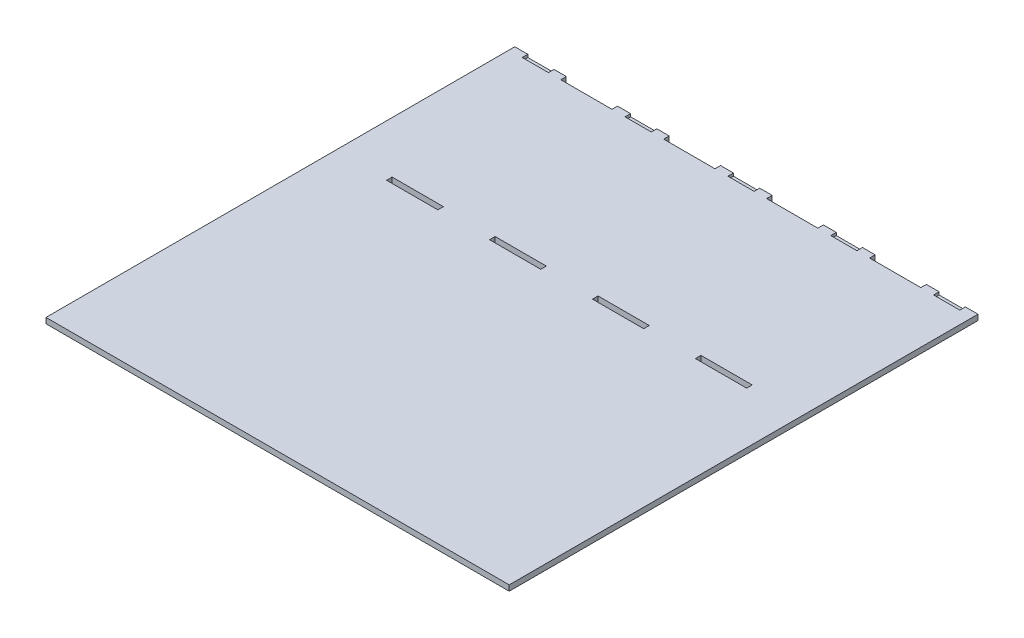
from build123d import *

# Parameters (mm, degrees)
SKETCH2_W              = 500
SKETCH2_H              = 506
BOSS_EXTRUDE1_DEPTH    = 6
CUT_EXTRUDE1_DEPTH     = 6
LPATTERN1_COUNT        = 4
LPATTERN1_PITCH        = 111.1
LPATTERN2_COUNT        = 2
LPATTERN2_PITCH        = 188
LPATTERN3_COPY_1_DEPTH = 6
LPATTERN3_COPY_2_DEPTH = 6
LPATTERN3_COPY_3_DEPTH = 6
SKETCH9_W              = 28.3
SKETCH9_H              = 6
CUT_EXTRUDE3_DEPTH     = 3
LPATTERN5_COUNT        = 5
LPATTERN5_PITCH        = 111


with BuildPart() as part:
    # Sketch2 → Boss-Extrude1 (new body)
    with BuildSketch(Plane(origin=(0, 0, 0), x_dir=(1, 0, 0), z_dir=(0, 1, 0))):
        Rectangle(SKETCH2_W, SKETCH2_H)
    extrude(amount=BOSS_EXTRUDE1_DEPTH)

    # Sketch3 → Cut-Extrude1 (cut)
    with BuildSketch(Plane(origin=(0, 6, 0), x_dir=(1, 0, 0), z_dir=(0, 1, 0))):
        with BuildLine():
            add(Edge.make_bspline(
                [(194.4, 253), (194.2, 253), (194.2, 250), (194.2, 247), (194.4, 247)],
                knots=[3.141592654, 3.141592654, 3.141592654, 4.71238898, 4.71238898, 6.283185307, 6.283185307, 6.283185307], degree=2, weights=[1, 0.707106781, 1, 0.707106781, 1]))
            Line((194.4, 253), (138.8, 253))
            add(Edge.make_bspline(
                [(138.8, 247), (139, 247), (139, 250), (139, 253), (138.8, 253)],
                knots=[0, 0, 0, 1.570796327, 1.570796327, 3.141592654, 3.141592654, 3.141592654], degree=2, weights=[1, 0.707106781, 1, 0.707106781, 1]))
            Line((138.8, 247), (194.4, 247))
        make_face()
    cut_extrude1 = extrude(amount=-CUT_EXTRUDE1_DEPTH, mode=Mode.SUBTRACT)

    # LPattern1: Cut-Extrude1 ×4
    with Locations(*[(-i * LPATTERN1_PITCH, 0, 0) for i in range(1, LPATTERN1_COUNT)]):
        add(cut_extrude1, mode=Mode.SUBTRACT)

    # LPattern2: Cut-Extrude1 ×2
    with Locations(*[(0, 0, i * LPATTERN2_PITCH) for i in range(1, LPATTERN2_COUNT)]):
        add(cut_extrude1, mode=Mode.SUBTRACT)

    # LPattern3 copy 1 sketch → LPattern3 copy 1 (cut)
    with BuildSketch(Plane(origin=(-111.1, 6, 188), x_dir=(1, 0, 0), z_dir=(0, 1, 0))):
        with BuildLine():
            add(Edge.make_bspline(
                [(194.4, 253), (194.2, 253), (194.2, 250), (194.2, 247), (194.4, 247)],
                knots=[3.141592654, 3.141592654, 3.141592654, 4.71238898, 4.71238898, 6.283185307, 6.283185307, 6.283185307], degree=2, weights=[1, 0.707106781, 1, 0.707106781, 1]))
            Line((194.4, 253), (138.8, 253))
            add(Edge.make_bspline(
                [(138.8, 247), (139, 247), (139, 250), (139, 253), (138.8, 253)],
                knots=[0, 0, 0, 1.570796327, 1.570796327, 3.141592654, 3.141592654, 3.141592654], degree=2, weights=[1, 0.707106781, 1, 0.707106781, 1]))
            Line((138.8, 247), (194.4, 247))
        make_face()
    extrude(amount=-LPATTERN3_COPY_1_DEPTH, mode=Mode.SUBTRACT)

    # LPattern3 copy 2 sketch → LPattern3 copy 2 (cut)
    with BuildSketch(Plane(origin=(-222.2, 6, 188), x_dir=(1, 0, 0), z_dir=(0, 1, 0))):
        with BuildLine():
            add(Edge.make_bspline(
                [(194.4, 253), (194.2, 253), (194.2, 250), (194.2, 247), (194.4, 247)],
                knots=[3.141592654, 3.141592654, 3.141592654, 4.71238898, 4.71238898, 6.283185307, 6.283185307, 6.283185307], degree=2, weights=[1, 0.707106781, 1, 0.707106781, 1]))
            Line((194.4, 253), (138.8, 253))
            add(Edge.make_bspline(
                [(138.8, 247), (139, 247), (139, 250), (139, 253), (138.8, 253)],
                knots=[0, 0, 0, 1.570796327, 1.570796327, 3.141592654, 3.141592654, 3.141592654], degree=2, weights=[1, 0.707106781, 1, 0.707106781, 1]))
            Line((138.8, 247), (194.4, 247))
        make_face()
    extrude(amount=-LPATTERN3_COPY_2_DEPTH, mode=Mode.SUBTRACT)

    # LPattern3 copy 3 sketch → LPattern3 copy 3 (cut)
    with BuildSketch(Plane(origin=(-333.3, 6, 188), x_dir=(1, 0, 0), z_dir=(0, 1, 0))):
        with BuildLine():
            add(Edge.make_bspline(
                [(194.4, 253), (194.2, 253), (194.2, 250), (194.2, 247), (194.4, 247)],
                knots=[3.141592654, 3.141592654, 3.141592654, 4.71238898, 4.71238898, 6.283185307, 6.283185307, 6.283185307], degree=2, weights=[1, 0.707106781, 1, 0.707106781, 1]))
            Line((194.4, 253), (138.8, 253))
            add(Edge.make_bspline(
                [(138.8, 247), (139, 247), (139, 250), (139, 253), (138.8, 253)],
                knots=[0, 0, 0, 1.570796327, 1.570796327, 3.141592654, 3.141592654, 3.141592654], degree=2, weights=[1, 0.707106781, 1, 0.707106781, 1]))
            Line((138.8, 247), (194.4, 247))
        make_face()
    extrude(amount=-LPATTERN3_COPY_3_DEPTH, mode=Mode.SUBTRACT)

    # Sketch9 → Cut-Extrude3 (cut)
    with BuildSketch(Plane(origin=(0, 6, 0), x_dir=(1, 0, 0), z_dir=(0, 1, 0))):
        with Locations((222.2, 250)):
            Rectangle(SKETCH9_W, SKETCH9_H)
    cut_extrude3 = extrude(amount=-CUT_EXTRUDE3_DEPTH, mode=Mode.SUBTRACT)

    # LPattern5: Cut-Extrude3 ×5
    with Locations(*[(-i * LPATTERN5_PITCH, 0, 0) for i in range(1, LPATTERN5_COUNT)]):
        add(cut_extrude3, mode=Mode.SUBTRACT)


solid = part.part
